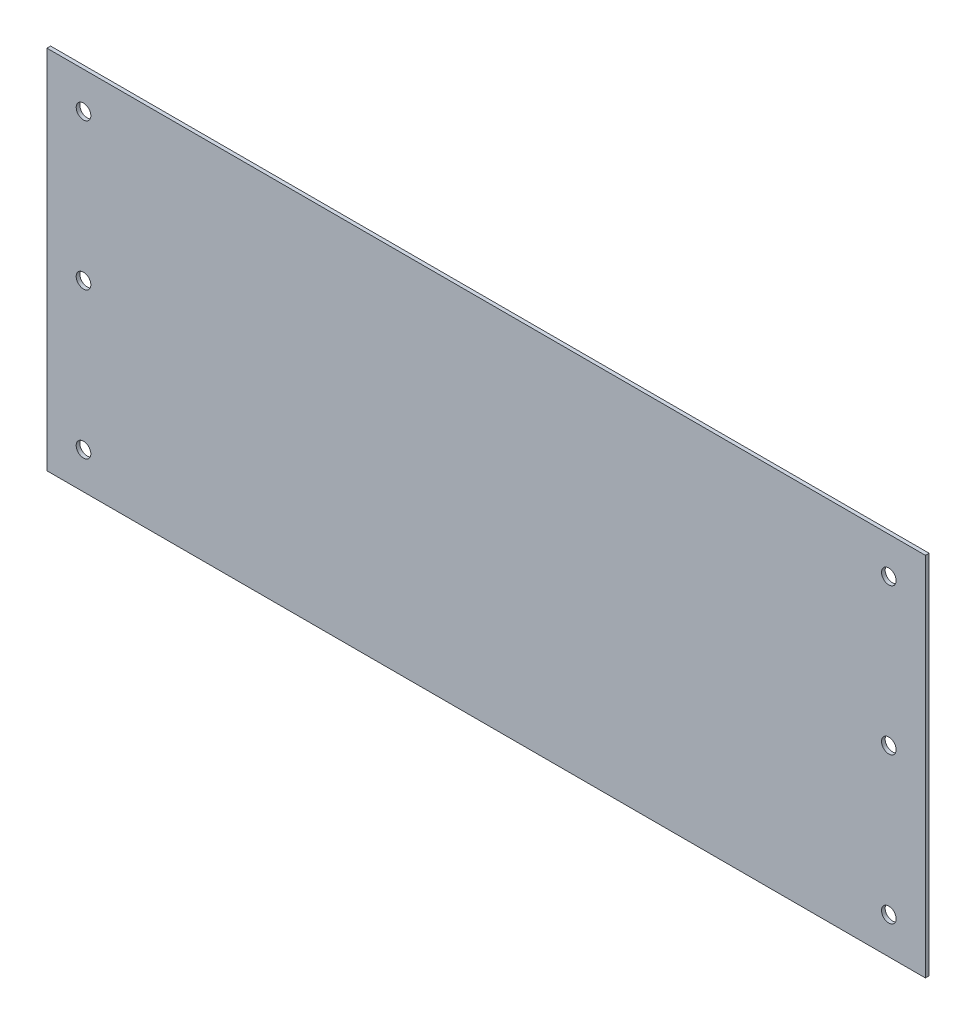
from build123d import *

# Parameters (mm, degrees)
SKETCH1_W           = 240
SKETCH1_H           = 100
BOSS_EXTRUDE1_DEPTH = 1
SKETCH2_R           = 2
CUT_EXTRUDE1_DEPTH  = 2


with BuildPart() as part:
    # Sketch1 → Boss-Extrude1 (new body)
    with BuildSketch(Plane.XY):
        with Locations((-100, 50)):
            Rectangle(SKETCH1_W, SKETCH1_H)
    extrude(amount=BOSS_EXTRUDE1_DEPTH)

    # Sketch2 → Cut-Extrude1 (cut, through all)
    with BuildSketch(Plane.XY.offset(1)):
        with Locations((10, 90)):
            Circle(SKETCH2_R)
        with Locations((10, 50)):
            Circle(SKETCH2_R)
        with Locations((10, 10)):
            Circle(SKETCH2_R)
        with Locations((-210, 10)):
            Circle(SKETCH2_R)
        with Locations((-210, 50)):
            Circle(SKETCH2_R)
        with Locations((-210, 90)):
            Circle(SKETCH2_R)
    extrude(amount=-CUT_EXTRUDE1_DEPTH, mode=Mode.SUBTRACT)


solid = part.part
